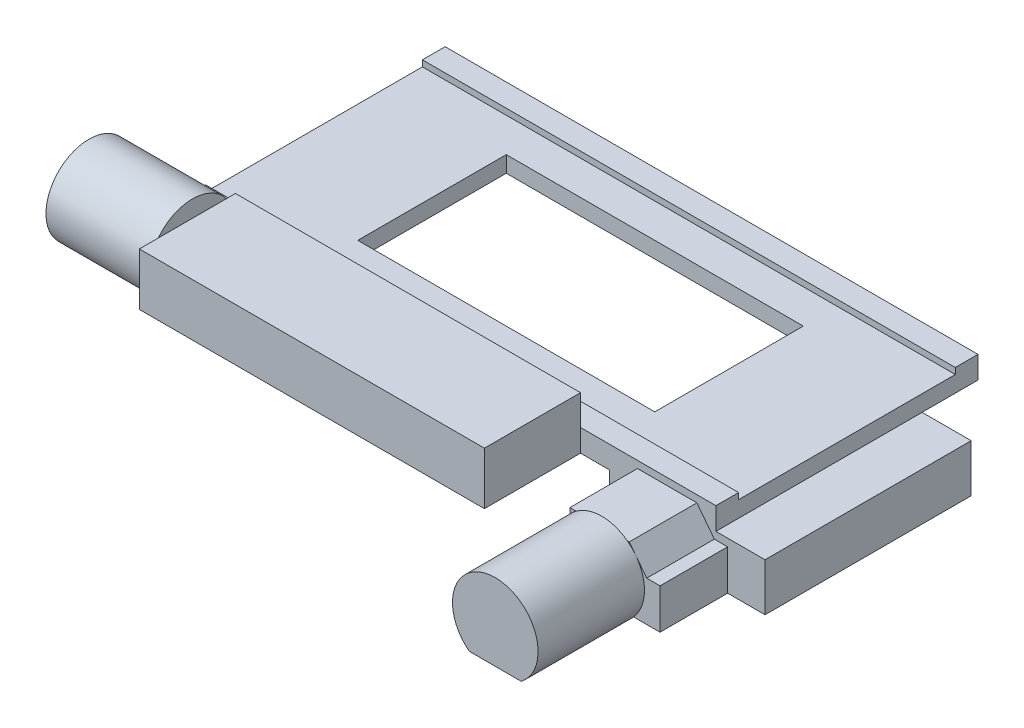
from build123d import *

# Parameters (mm, degrees)
SKETCH2_W           = 305
SKETCH2_H           = 150
BOSS_EXTRUDE1_DEPTH = 6.375
SKETCH3_W           = 124
SKETCH3_H           = 3.5
CUT_EXTRUDE1_DEPTH  = 306
SKETCH4_W           = 197.5
SKETCH4_H           = 30
BOSS_EXTRUDE2_DEPTH = 55
BOSS_EXTRUDE3_DEPTH = 59.2
SKETCH6_W           = 73
SKETCH6_H           = 118
BOSS_EXTRUDE4_DEPTH = 27.3
BOSS_EXTRUDE5_DEPTH = 38.7
BOSS_EXTRUDE6_DEPTH = 60.9
SKETCH9_W           = 16
SKETCH9_H           = 150
BOSS_EXTRUDE7_DEPTH = 9
SKETCH10_W          = 170
SKETCH10_H          = 85
CUT_EXTRUDE2_DEPTH  = 40.7


with BuildPart() as part:
    # Sketch2 → Boss-Extrude1 (new body, symmetric)
    with BuildSketch(Plane(origin=(0, 0, 0), x_dir=(1, 0, 0), z_dir=(0, 1, 0))):
        Rectangle(SKETCH2_W, SKETCH2_H)
    extrude(amount=BOSS_EXTRUDE1_DEPTH, both=True)

    # Sketch3 → Cut-Extrude1 (cut, through all)
    with BuildSketch(Plane(origin=(152.5, 0, 0), x_dir=(0, 0, -1), z_dir=(1, 0, 0))):
        with Locations((0, 4.625)):
            Rectangle(SKETCH3_W, SKETCH3_H)
    extrude(amount=-CUT_EXTRUDE1_DEPTH, mode=Mode.SUBTRACT)

    # Sketch4 → Boss-Extrude2 (add)
    with BuildSketch(Plane.XY.offset(75)):
        with Locations((-23.75, 8.625)):
            Rectangle(SKETCH4_W, SKETCH4_H)
    extrude(amount=BOSS_EXTRUDE2_DEPTH)

    # Sketch5 → Boss-Extrude3 (add)
    with BuildSketch(Plane.ZY.offset(122.5)):
        with BuildLine():
            Line((84.426315846, -10.75), (114.823684154, -10.75))
            ThreePointArc((114.823684154, -10.75), (99.625, 33.25), (84.426315846, -10.75))
        make_face()
    extrude(amount=BOSS_EXTRUDE3_DEPTH)

    # Sketch6 → Boss-Extrude4 (add)
    with BuildSketch(Plane.XZ.offset(6.375)):
        with Locations((144.1, 16)):
            Rectangle(SKETCH6_W, SKETCH6_H)
    extrude(amount=BOSS_EXTRUDE4_DEPTH)

    # Sketch7 → Boss-Extrude5 (add)
    with BuildSketch(Plane.XY.offset(75)):
        Polygon((107.6, -33.675), (107.6, 2.325), (141.6, 2.325), (151.6, -10.675), (159.2, -10.675), (159.2, -33.675), align=None)
    extrude(amount=BOSS_EXTRUDE5_DEPTH)

    # Sketch8 → Boss-Extrude6 (add)
    with BuildSketch(Plane.XY.offset(113.7)):
        with BuildLine():
            Line((110.972997108, -36.825), (140.637791056, -36.825))
            ThreePointArc((140.637791056, -36.825), (125.805394082, 7.175), (110.972997108, -36.825))
        make_face()
    extrude(amount=BOSS_EXTRUDE6_DEPTH)

    # Sketch9 → Boss-Extrude7 (add)
    with BuildSketch(Plane.XZ.offset(6.375)):
        with Locations((-130.5, 0)):
            Rectangle(SKETCH9_W, SKETCH9_H)
        with Locations((99.6, 0)):
            Rectangle(SKETCH9_W, SKETCH9_H)
    extrude(amount=BOSS_EXTRUDE7_DEPTH)

    # Sketch10 → Cut-Extrude2 (cut, through all)
    with BuildSketch(Plane(origin=(0, 2.875, 0), x_dir=(1, 0, 0), z_dir=(0, 1, 0))):
        Rectangle(SKETCH10_W, SKETCH10_H)
    extrude(amount=-CUT_EXTRUDE2_DEPTH, mode=Mode.SUBTRACT)


solid = part.part
